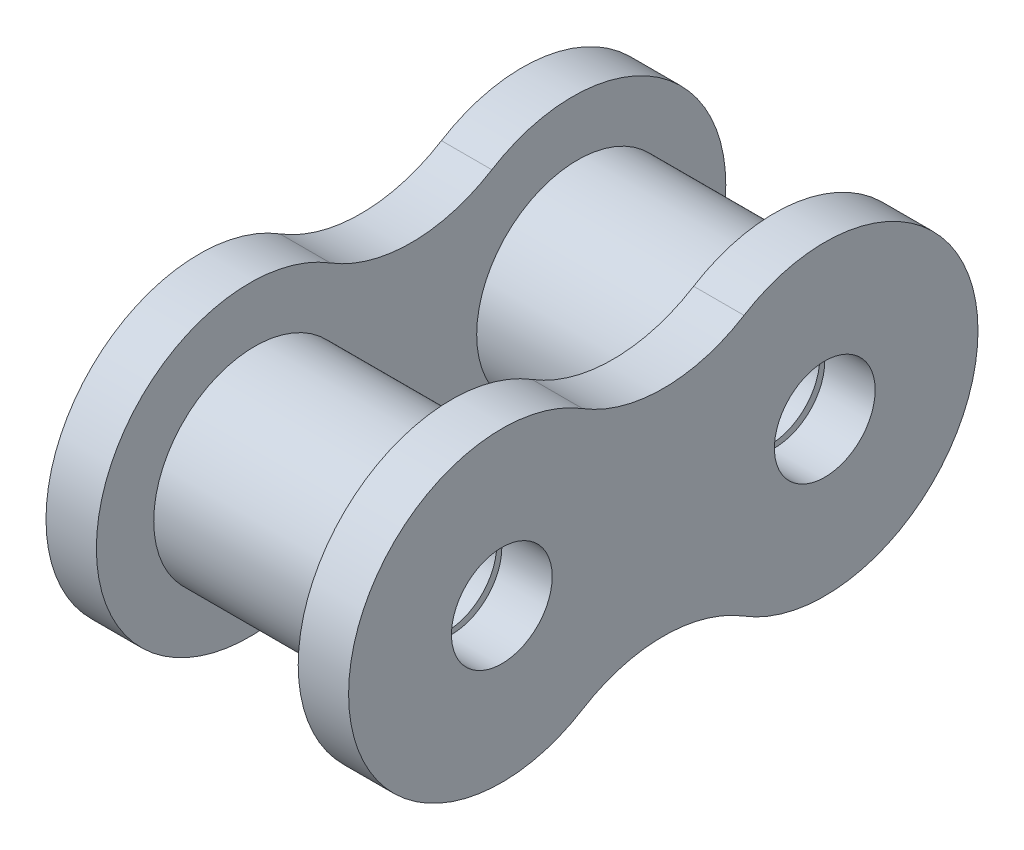
from build123d import *

# Parameters (mm, degrees)
BACK_LINK_SKETCH_R          = 3.9624
BACK_LINK_EXTRUDE_DEPTH     = 3.9624
FRONT_LINK_SKETCH_R         = 3.9624
FRONT_LINK_EXTRUDE_DEPTH    = 3.9624
ROLLER_SKETCH_R             = 7.9375
ROLLER_SKETCH_R_2           = 3.9624
ROLLER_EXTRUDE_DEPTH        = 7.540625
ROLLER_EXTRUDE_DEPTH_BACK   = 7.540625
ROLLER_EXTRUDE_2_DEPTH      = 7.540625
ROLLER_EXTRUDE_2_DEPTH_BACK = 7.540625


with BuildPart() as part:
    # Back Link Sketch → Back Link Extrude (new body)
    with BuildSketch(Plane(origin=(-7.9375, 0, 0), x_dir=(0, 0, -1), z_dir=(1, 0, 0))):
        with BuildLine():
            ThreePointArc((-6.35, 10.243799846), (-24.7523, 0), (-6.35, -10.243799846))
            ThreePointArc((-6.35, -10.243799846), (0, -8.435299692), (6.35, -10.243799846))
            ThreePointArc((6.35, -10.243799846), (24.7523, 0), (6.35, 10.243799846))
            ThreePointArc((6.35, 10.243799846), (0, 8.435299692), (-6.35, 10.243799846))
        make_face()
        with Locations((-12.7, 0)):
            Circle(BACK_LINK_SKETCH_R, mode=Mode.SUBTRACT)
        with Locations((12.7, 0)):
            Circle(BACK_LINK_SKETCH_R, mode=Mode.SUBTRACT)
    extrude(amount=-BACK_LINK_EXTRUDE_DEPTH)


with BuildPart() as body_2:
    # Front Link Sketch → Front Link Extrude (new body)
    with BuildSketch(Plane(origin=(7.9375, 0, 0), x_dir=(0, 0, -1), z_dir=(1, 0, 0))):
        with BuildLine():
            ThreePointArc((-6.35, 10.243799846), (0, 8.435299692), (6.35, 10.243799846))
            ThreePointArc((6.35, 10.243799846), (24.7523, 0), (6.35, -10.243799846))
            ThreePointArc((6.35, -10.243799846), (0, -8.435299692), (-6.35, -10.243799846))
            ThreePointArc((-6.35, -10.243799846), (-24.7523, 0), (-6.35, 10.243799846))
        make_face()
        with Locations((-12.7, 0)):
            Circle(FRONT_LINK_SKETCH_R, mode=Mode.SUBTRACT)
        with Locations((12.7, 0)):
            Circle(FRONT_LINK_SKETCH_R, mode=Mode.SUBTRACT)
    extrude(amount=FRONT_LINK_EXTRUDE_DEPTH)


with BuildPart() as body_3:
    # Roller Sketch → Roller Extrude (new body, two sides)
    with BuildSketch(Plane(origin=(0, 0, 0), x_dir=(0, 0, -1), z_dir=(1, 0, 0))) as roller_extrude_sk:
        with Locations((12.7, 0)):
            Circle(ROLLER_SKETCH_R)
        with Locations((12.7, 0)):
            Circle(ROLLER_SKETCH_R_2, mode=Mode.SUBTRACT)
    extrude(amount=ROLLER_EXTRUDE_DEPTH)
    extrude(roller_extrude_sk.sketch, amount=-ROLLER_EXTRUDE_DEPTH_BACK)


with BuildPart() as body_4:
    # Roller Sketch → Roller Extrude 2 (new body, two sides)
    with BuildSketch(Plane(origin=(0, 0, 0), x_dir=(0, 0, -1), z_dir=(1, 0, 0))) as roller_extrude_2_sk:
        with Locations((-12.7, 0)):
            Circle(ROLLER_SKETCH_R)
        with Locations((-12.7, 0)):
            Circle(ROLLER_SKETCH_R_2, mode=Mode.SUBTRACT)
    extrude(amount=ROLLER_EXTRUDE_2_DEPTH)
    extrude(roller_extrude_2_sk.sketch, amount=-ROLLER_EXTRUDE_2_DEPTH_BACK)


solid = Compound([part.part, body_2.part, body_3.part, body_4.part])
